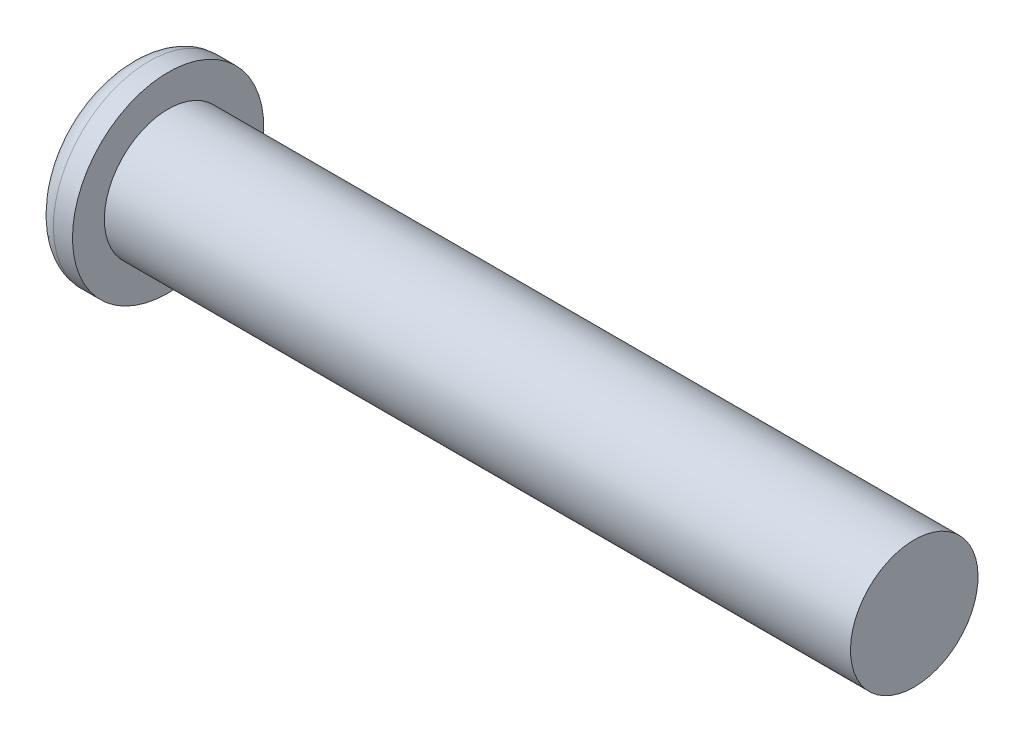
from build123d import *

# Parameters (mm, degrees)
DOME1_FACE_RADIUS = 7.5
DOME1_HEIGHT      = 3


with BuildPart() as part:
    # Sketch1 → Revolve1 (revolve)
    with BuildSketch(Plane.XY):
        Polygon((58.5, 0), (58.5, 5), (0, 5), (0, 7.5), (-1.5, 7.5), (-1.5, 0), align=None)
    revolve(axis=Axis((0, 0, 0), (1, 0, 0)))

    # Dome1: an elliptical dome of height H over a round flat face of radius A is half a spheroid: the quarter ellipse of half axes A and H revolved about the face's axis
    with BuildSketch(Plane((-1.5, 0, 0), x_dir=(0, 0, -1), z_dir=(0, 1, 0)), mode=Mode.PRIVATE) as dome1_quarter:
        Ellipse(DOME1_FACE_RADIUS, DOME1_HEIGHT)
        Rectangle(DOME1_FACE_RADIUS, DOME1_HEIGHT, align=(Align.MIN, Align.MIN), mode=Mode.INTERSECT)
    revolve(dome1_quarter.sketch, axis=Axis((-1.5, 0, 0), (-1, 0, 0)))


solid = part.part
